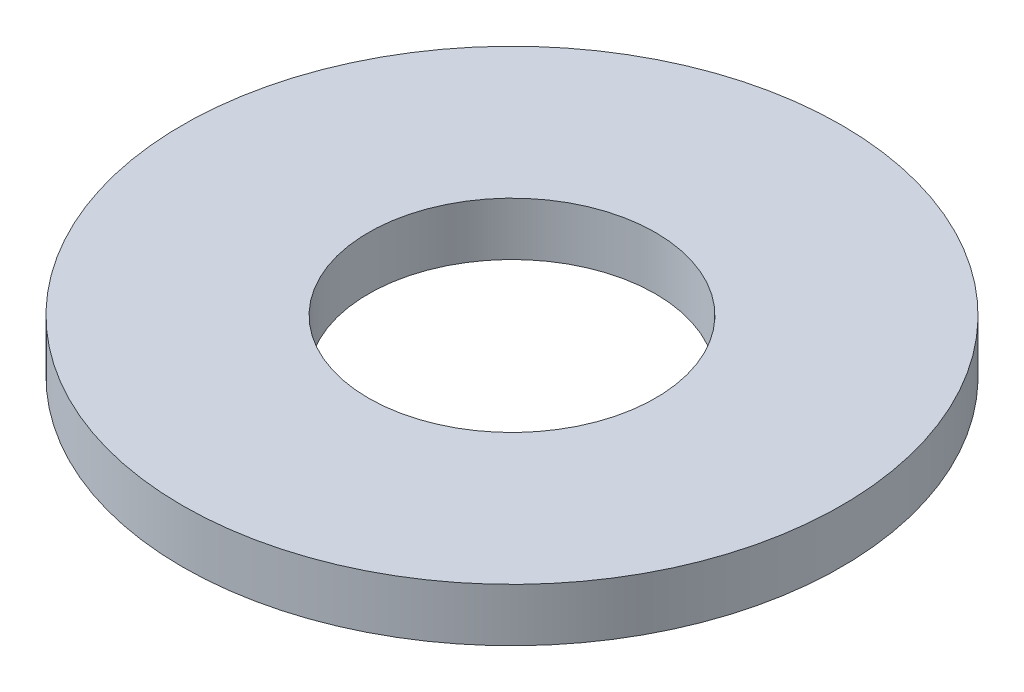
from build123d import *

# Parameters (mm, degrees)
SKETCH1_R      = 3.1
SKETCH1_R_2    = 1.35
EXTRUDE1_DEPTH = 0.5


with BuildPart() as part:
    # Sketch1 → Extrude1 (new body)
    with BuildSketch(Plane(origin=(0, 0, 0), x_dir=(1, 0, 0), z_dir=(0, 1, 0))):
        with Locations(Location((0, 0, 0), (0, 0, 270))):  # turned: the seam where the file's is
            Circle(SKETCH1_R)
        with Locations(Location((0, 0, 0), (0, 0, 270))):  # turned: the seam where the file's is
            Circle(SKETCH1_R_2, mode=Mode.SUBTRACT)
    extrude(amount=EXTRUDE1_DEPTH)


solid = part.part
